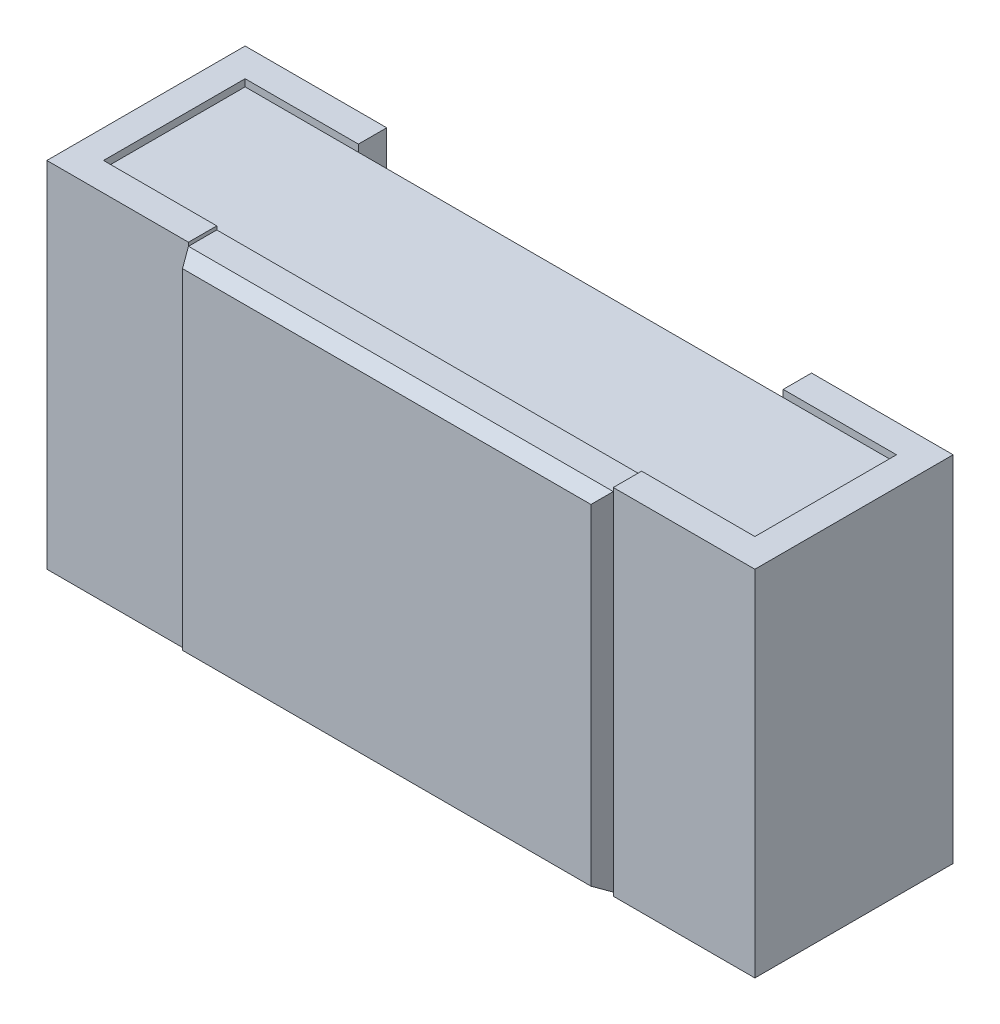
from build123d import *

# Parameters (mm, degrees)
EXTRUDE_START             = 0.04
SKETCH_2_W                = 0.92
SKETCH_2_H                = 0.48
EXTRUDE_2_DEPTH           = 0.2
EXTRUDE_4_DEPTH           = 0.25
EXTRUDE_4_DEPTH_BACK      = 0.25
EXTRUDE_START_2           = 0.28
SKETCH_6_W                = 0.6
SKETCH_6_H                = 0.49
EXTRUDE_6_DEPTH           = 0.02
EXTRUDE_6_TAPER           = 30
EXTRUDE_6_OTHER_WAY_DEPTH = 0.04


with BuildPart() as part:
    # Эскиз2 → Вытянуть2 (new body)
    with BuildSketch(Plane.XY.offset(EXTRUDE_START)):
        Rectangle(SKETCH_2_W, SKETCH_2_H)
    extrude(amount=EXTRUDE_2_DEPTH)

    # Эскиз4 → Вытянуть4 (add, two sides)
    with BuildSketch(Plane(origin=(0, 0, 0), x_dir=(1, 0, 0), z_dir=(0, 1, 0))) as extrude_4_sk:
        Polygon((-0.5, 0), (-0.3, 0), (-0.3, -0.04), (-0.46, -0.04), (-0.46, -0.24), (-0.3, -0.24), (-0.3, -0.28), (-0.5, -0.28), align=None)
        Polygon((0.3, -0.24), (0.46, -0.24), (0.46, -0.04), (0.3, -0.04), (0.3, 0), (0.5, 0), (0.5, -0.28), (0.3, -0.28), align=None)
    extrude(amount=EXTRUDE_4_DEPTH)
    extrude(extrude_4_sk.sketch, amount=-EXTRUDE_4_DEPTH_BACK)

    # Эскиз6 → Вытянуть6 (add)
    with BuildSketch(Plane.XY.offset(EXTRUDE_START_2)):
        Rectangle(SKETCH_6_W, SKETCH_6_H)
    extrude(amount=EXTRUDE_6_DEPTH, taper=EXTRUDE_6_TAPER)

    # Эскиз6 → Вытянуть6 other way (add)
    with BuildSketch(Plane.XY.offset(EXTRUDE_START_2)):
        Rectangle(SKETCH_6_W, SKETCH_6_H)
    extrude(amount=-EXTRUDE_6_OTHER_WAY_DEPTH)


solid = part.part
